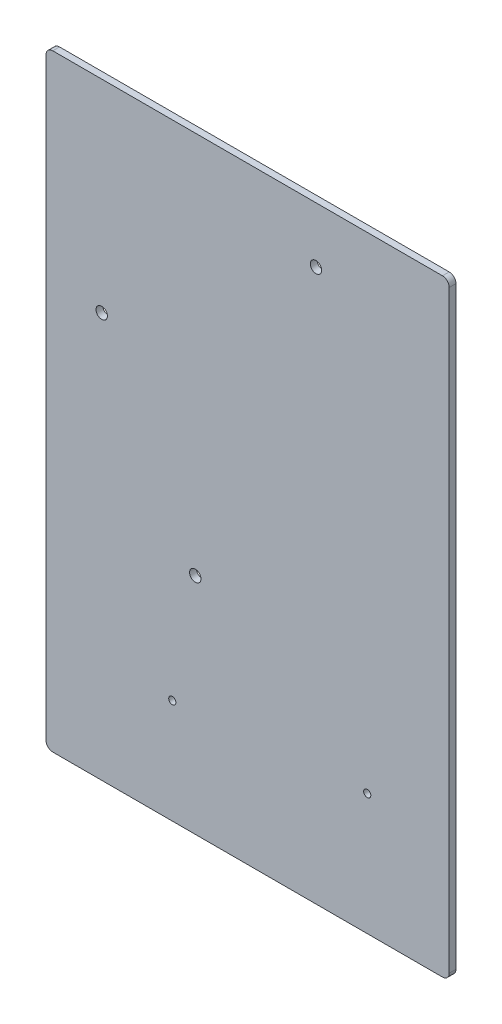
from build123d import *

# Parameters (mm, degrees)
BOSS_EXTRUDE1_DEPTH              = 6.35
FILLET1_R                        = 3.175
FILLET2_R                        = 44.45
F_1_4_CLEARANCE_HOLE1_D          = 6.7564
SKETCH4_W                        = 100.0125
SKETCH4_H                        = 155.575
CUT_EXTRUDE1_DEPTH               = 7.35
F_27_64_0_42188_DIAMETER_HOLE1_D = 10.715752
FILLET3_R                        = 6.35


with BuildPart() as part:
    # Sketch1 → Boss-Extrude1 (new body)
    with BuildSketch(Plane.XY):
        Polygon((0, 0), (0, 571.5), (379.4125, 571.5), (379.4125, 466.725), (479.425, 466.725), (479.425, 355.6), (428.625, 355.6), (428.625, 403.225), (379.4125, 403.225), (379.4125, 0), align=None)
    extrude(amount=BOSS_EXTRUDE1_DEPTH)

    # Fillet1
    fillet1_edges = [part.edges().sort_by_distance(p)[0] for p in [
        (428.625, 403.225, 3.175),
        (379.4125, 403.225, 3.175),
    ]]
    fillet(fillet1_edges, radius=FILLET1_R)

    # Fillet2
    fillet2_edges = [part.edges().sort_by_distance(p)[0] for p in [
        (379.4125, 466.725, 3.175),
        (479.425, 466.725, 3.175),
    ]]
    fillet(fillet2_edges, radius=FILLET2_R)

    # 1/4 Clearance Hole1 (through all)
    with Locations(Plane(origin=(0, 0, 0), x_dir=(-1, 0, 0), z_dir=(0, 0, -1))):
        with Locations((-118.810746346, 98.250269973), (-302.26, 114.3)):
            Hole(F_1_4_CLEARANCE_HOLE1_D / 2)

    # Sketch4 → Cut-Extrude1 (cut, through all)
    with BuildSketch(Plane(origin=(0, 0, 0), x_dir=(-1, 0, 0), z_dir=(0, 0, -1))):
        with Locations((-429.41875, 433.3875)):
            Rectangle(SKETCH4_W, SKETCH4_H)
    extrude(amount=-CUT_EXTRUDE1_DEPTH, mode=Mode.SUBTRACT)

    # 27/64 (0.42188) Diameter Hole1 (through all)
    with Locations(Plane(origin=(0, 0, 0), x_dir=(-1, 0, 0), z_dir=(0, 0, -1))):
        with Locations((-254, 519.1125), (-52.3875, 381), (-140.462, 210.82)):
            Hole(F_27_64_0_42188_DIAMETER_HOLE1_D / 2)

    # Fillet3
    fillet3_edges = [part.edges().sort_by_distance(p)[0] for p in [
        (0, 0, 3.175),
        (0, 571.5, 3.175),
        (379.4125, 571.5, 3.175),
        (379.4125, 0, 3.175),
    ]]
    fillet(fillet3_edges, radius=FILLET3_R)


solid = part.part
